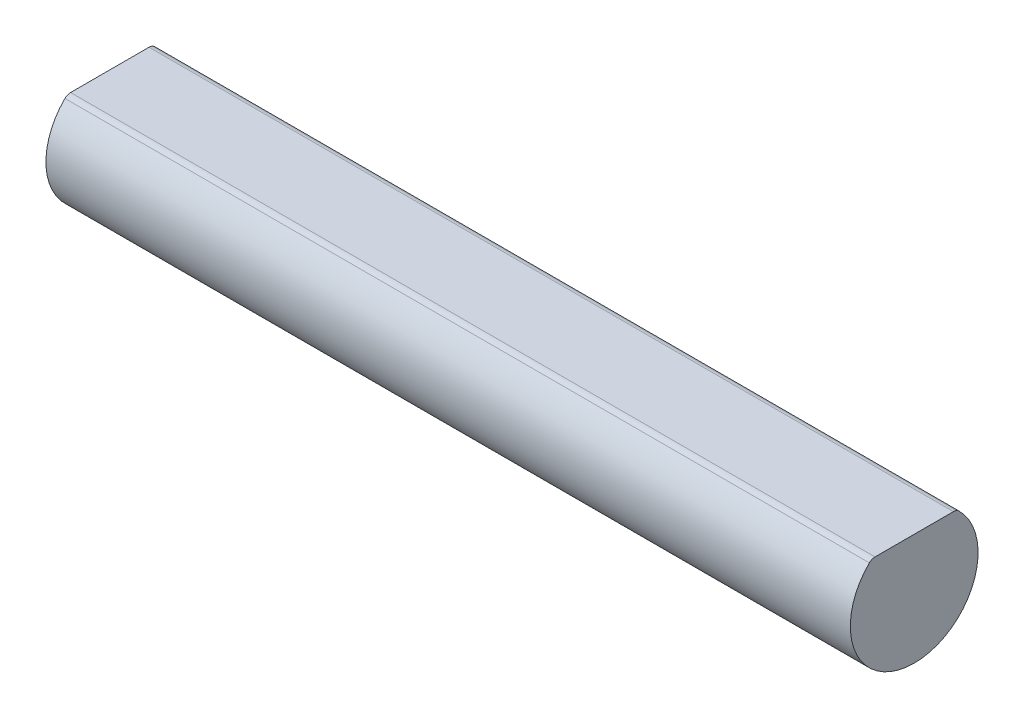
from build123d import *

# Parameters (mm, degrees)
SKETCH1_R           = 7.94
BOSS_EXTRUDE1_DEPTH = 100
SKETCH2_W           = 10.691765032
SKETCH2_H           = 3.27703882
SKETCH2_W_2         = 8.911923052
CUT_EXTRUDE1_DEPTH  = 101
FILLET1_R           = 1


with BuildPart() as part:
    # Sketch1 → Boss-Extrude1 (new body)
    with BuildSketch(Plane(origin=(0, 0, 0), x_dir=(0, 0, -1), z_dir=(1, 0, 0))):
        Circle(SKETCH1_R)
    extrude(amount=BOSS_EXTRUDE1_DEPTH)

    # Sketch2 → Cut-Extrude1 (cut, through all)
    with BuildSketch(Plane(origin=(100, 0, 0), x_dir=(0, 0, -1), z_dir=(1, 0, 0))):
        with Locations((-5.345882516, 7.57851941)):
            Rectangle(SKETCH2_W, SKETCH2_H)
        with Locations((4.455961526, 7.57851941)):
            Rectangle(SKETCH2_W_2, SKETCH2_H)
    extrude(amount=-CUT_EXTRUDE1_DEPTH, mode=Mode.SUBTRACT)

    # Fillet1
    fillet1_edges = [part.edges().sort_by_distance(p)[0] for p in [
        (50, 5.94, -5.268775949),
        (50, 5.94, 5.268775949),
    ]]
    fillet(fillet1_edges, radius=FILLET1_R)


solid = part.part
